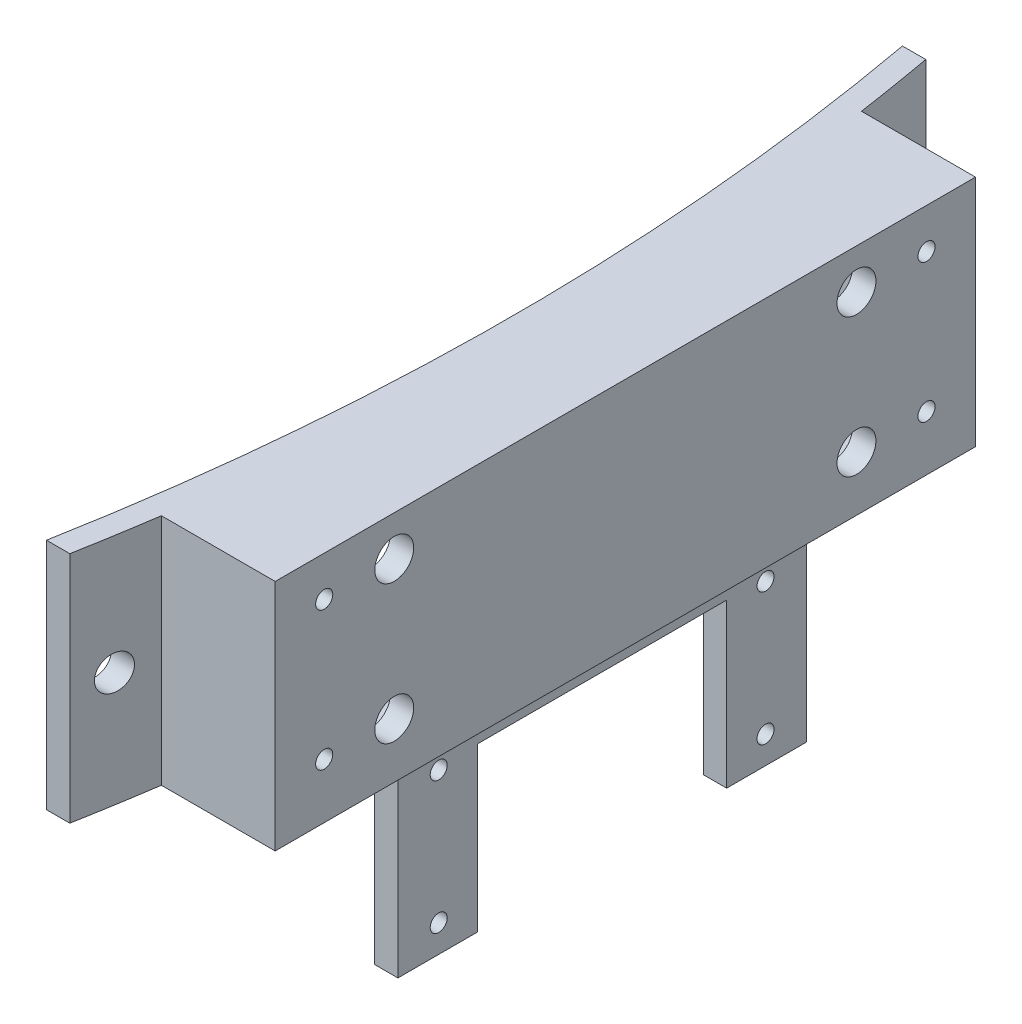
from build123d import *

# Parameters (mm, degrees)
EXTRUDE_1_DEPTH      = 10
EXTRUDE_1_DEPTH_BACK = 20
EXTRUDE_2_DEPTH      = 20
EXTRUDE_3_DEPTH      = 10
SKETCH_5_W           = 84
SKETCH_5_H           = 24
CUT_EXTRUDE_1_DEPTH  = 17
SKETCH_4_R           = 2.5
SKETCH_4_R_2         = 1.1
CUT_EXTRUDE_2_DEPTH  = 17
SKETCH_6_R           = 2.210367197
CUT_EXTRUDE_3_DEPTH  = 8
SKETCH_7_W           = 3
SKETCH_7_H           = 52.500208742
EXTRUDE_4_DEPTH      = 25
SKETCH_8_R           = 1.095411725
SKETCH_8_W           = 32
SKETCH_8_H           = 20.937005418
CUT_EXTRUDE_6_DEPTH  = 5


with BuildPart() as part:
    # Sketch 1 → Extrude 1 (new body, two sides)
    with BuildSketch(Plane(origin=(0, 0, 0), x_dir=(1, 0, 0), z_dir=(0, 1, 0))) as extrude_1_sk:
        with BuildLine():
            ThreePointArc((-4.68866799, 114.767541166), (0.26262686, 59.767541166), (-4.68866799, 4.767541166))
            Line((-4.68866799, 4.767541166), (-7.68866799, 4.767541166))
            ThreePointArc((-7.68866799, 4.767541166), (-2.68866799, 59.767541166), (-7.68866799, 114.767541166))
            Line((-7.68866799, 114.767541166), (-4.68866799, 114.767541166))
        make_face()
    extrude(amount=EXTRUDE_1_DEPTH)
    extrude(extrude_1_sk.sketch, amount=-EXTRUDE_1_DEPTH_BACK)



with BuildPart() as body_2:
    # Sketch 1_3 → Extrude 2 (new body)
    with BuildSketch(Plane(origin=(0, 0, 0), x_dir=(1, 0, 0), z_dir=(0, 1, 0))):
        with BuildLine():
            Line((11.598251721, 104.872295398), (-3.058464061, 104.872295398))
            ThreePointArc((-3.058464061, 104.872295398), (0.262608655, 59.873432048), (-3.027517025, 14.872295398))
            Line((-3.027517025, 14.872295398), (11.598251721, 14.872295398))
            Line((11.598251721, 14.872295398), (11.598251721, 104.872295398))
        make_face()
    extrude(amount=-EXTRUDE_2_DEPTH)


with BuildPart() as part_1:
    add(part.part)

    add(body_2.part)  # Extrude 3 merges body 2
    # Sketch 1_4 → Extrude 3 (add)
    with BuildSketch(Plane(origin=(0, 0, 0), x_dir=(1, 0, 0), z_dir=(0, 1, 0))):
        with BuildLine():
            Line((11.598251721, 104.872295398), (-3.058464061, 104.872295398))
            ThreePointArc((-3.058464061, 104.872295398), (0.262608655, 59.873432048), (-3.027517025, 14.872295398))
            Line((-3.027517025, 14.872295398), (11.598251721, 14.872295398))
            Line((11.598251721, 14.872295398), (11.598251721, 104.872295398))
        make_face()
    extrude(amount=EXTRUDE_3_DEPTH)

    # Sketch 5 → Cut-Extrude 1 (cut)
    with BuildSketch(Plane(origin=(-8.401748279, 0, 0), x_dir=(0, 0, -1), z_dir=(1, 0, 0))):
        with Locations((59.767541166, -5.056638817)):
            Rectangle(SKETCH_5_W, SKETCH_5_H)
    extrude(amount=CUT_EXTRUDE_1_DEPTH, mode=Mode.SUBTRACT)

    # Sketch 4 → Cut-Extrude 2 (cut)
    with BuildSketch(Plane(origin=(11.598251721, 0, 0), x_dir=(0, 0, -1), z_dir=(1, 0, 0))):
        with Locations((30.172295398, 4.863328118)):
            Circle(SKETCH_4_R)
        with Locations((89.572295398, 4.863328118)):
            Circle(SKETCH_4_R)
        with Locations((89.572295398, -12.936671882)):
            Circle(SKETCH_4_R)
        with Locations((30.172295398, -12.936671882)):
            Circle(SKETCH_4_R)
        with Locations((21.172295398, -12.936671882)):
            Circle(SKETCH_4_R_2)
        with Locations((21.172295398, 4.863328118)):
            Circle(SKETCH_4_R_2)
        with Locations((98.572295398, 4.863328118)):
            Circle(SKETCH_4_R_2)
        with Locations((98.572295398, -12.936671882)):
            Circle(SKETCH_4_R_2)
    extrude(amount=-CUT_EXTRUDE_2_DEPTH, mode=Mode.SUBTRACT)

    # Sketch 6 → Cut-Extrude 3 (cut)
    with BuildSketch(Plane(origin=(-8.401748279, 0, 0), x_dir=(0, 0, -1), z_dir=(1, 0, 0))):
        with Locations(Location((9.665216794, -5.258703912, 0), (0, 0, 180))):  # turned: the seam where the file's is
            Circle(SKETCH_6_R)
        with Locations(Location((110.079374003, -5.258703912, 0), (0, 0, 180))):  # turned: the seam where the file's is
            Circle(SKETCH_6_R)
    extrude(amount=CUT_EXTRUDE_3_DEPTH, mode=Mode.SUBTRACT)

    # Sketch 7 → Extrude 4 (add)
    with BuildSketch(Plane.XZ.offset(20)):
        with Locations((7.115575895, -59.872295398)):
            Rectangle(SKETCH_7_W, SKETCH_7_H)
    extrude(amount=EXTRUDE_4_DEPTH)

    # Sketch 8 → Cut-Extrude 6 (cut)
    with BuildSketch(Plane(origin=(8.615575895, 0, 0), x_dir=(0, 0, -1), z_dir=(1, 0, 0))):
        with Locations((38.872295398, -24.471390048)):
            Circle(SKETCH_8_R)
        with Locations((38.872295398, -41.471390048)):
            Circle(SKETCH_8_R)
        with Locations((80.872295398, -41.471390048)):
            Circle(SKETCH_8_R)
        with Locations((80.872295398, -24.471390048)):
            Circle(SKETCH_8_R)
        with Locations((59.872295398, -34.531497291)):
            Rectangle(SKETCH_8_W, SKETCH_8_H)
    extrude(amount=-CUT_EXTRUDE_6_DEPTH, mode=Mode.SUBTRACT)


solid = part_1.part
